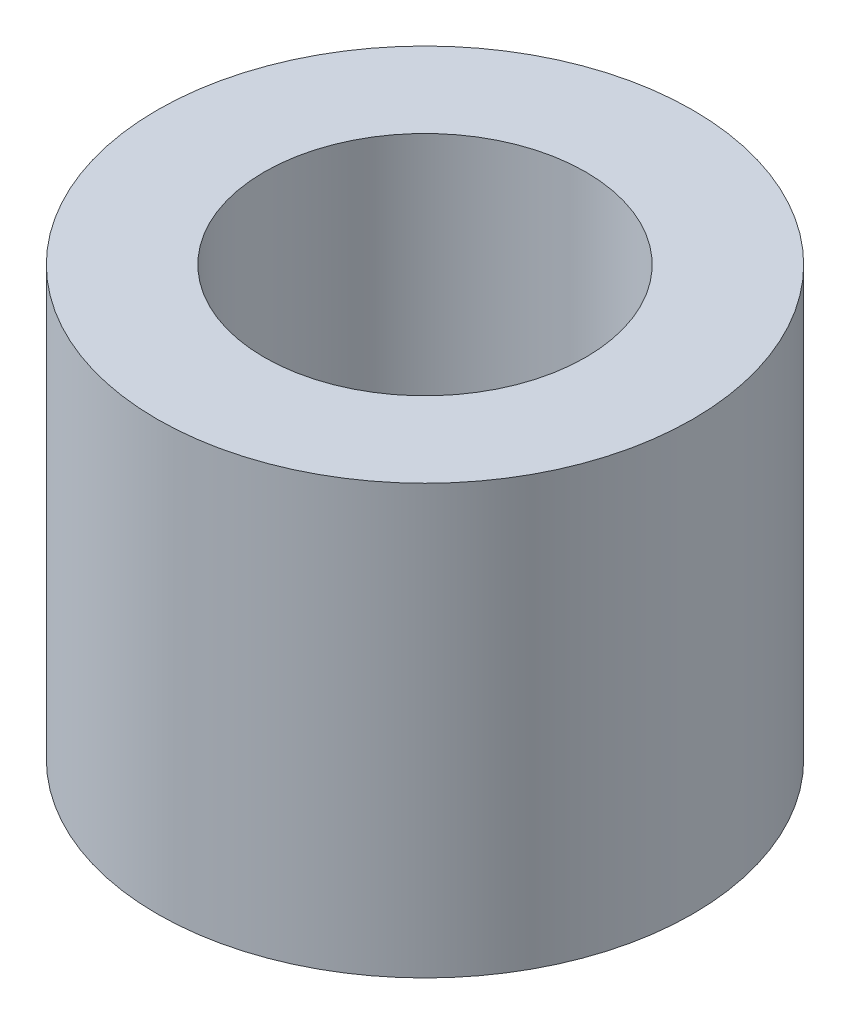
from build123d import *

# Parameters (mm, degrees)
SKETCH1_R           = 2.5
SKETCH1_R_2         = 1.5
BOSS_EXTRUDE1_DEPTH = 4


with BuildPart() as part:
    # Sketch1 → Boss-Extrude1 (new body)
    with BuildSketch(Plane(origin=(0, 0, 0), x_dir=(1, 0, 0), z_dir=(0, 1, 0))):
        Circle(SKETCH1_R)
        Circle(SKETCH1_R_2, mode=Mode.SUBTRACT)
    extrude(amount=BOSS_EXTRUDE1_DEPTH)


solid = part.part
